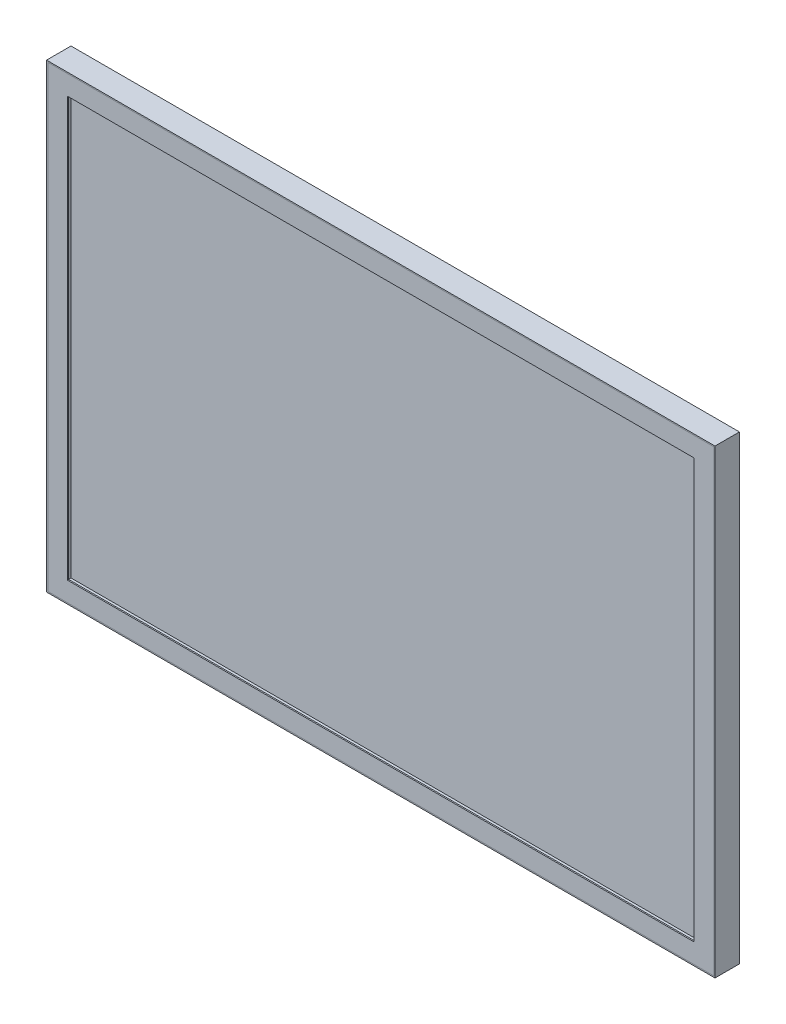
from build123d import *

# Parameters (mm, degrees)
SKETCH_1_W      = 547
SKETCH_1_H      = 377
EXTRUDE_1_DEPTH = 20
SHELL_1_T       = -1
SKETCH_3_W      = 545
SKETCH_3_H      = 375
SKETCH_3_W_2    = 513
SKETCH_3_H_2    = 343
EXTRUDE_2_DEPTH = 1


with BuildPart() as part:
    # 草图1 → 凸台-拉伸1 (new body)
    with BuildSketch(Plane.XY):
        Rectangle(SKETCH_1_W, SKETCH_1_H)
    extrude(amount=EXTRUDE_1_DEPTH)

    # 抽壳1
    shell_1_openings = [part.faces().sort_by_distance(p)[0] for p in [
        (0, 0, 20),
    ]]
    offset(amount=SHELL_1_T, openings=shell_1_openings, kind=Kind.INTERSECTION)


with BuildPart() as body_2:
    # 草图3 → 凸台-拉伸2 (new body)
    with BuildSketch(Plane.XY.offset(20)):
        Rectangle(SKETCH_3_W, SKETCH_3_H)
        Rectangle(SKETCH_3_W_2, SKETCH_3_H_2, mode=Mode.SUBTRACT)
    extrude(amount=-EXTRUDE_2_DEPTH)


solid = Compound([part.part, body_2.part])
